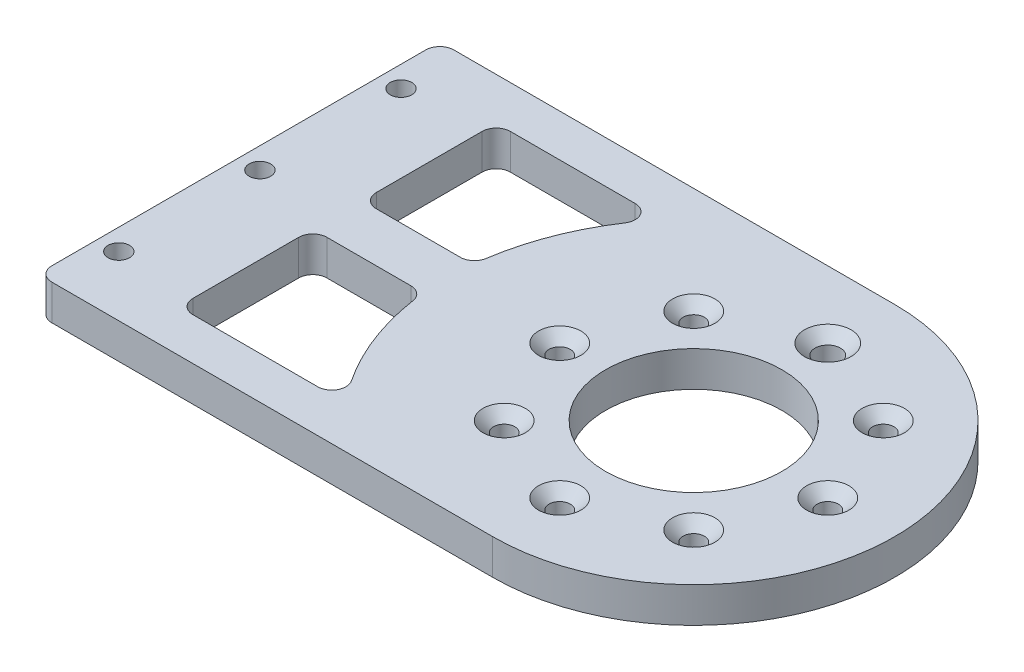
from build123d import *

# Parameters (mm, degrees)
EXTRUDE_1_DEPTH              = 5
SKETCH_2_R                   = 1.275
CUT_EXTRUDE_1_DEPTH          = 6
SKETCH_5_R                   = 10
CUT_EXTRUDE_3_DEPTH          = 6
SKETCH_6_R                   = 1.525
CUT_EXTRUDE_4_DEPTH          = 6
SKETCH_9_R                   = 12.5
CUT_EXTRUDE_7_DEPTH          = 6
HOLE_WIZARD_M3_1_D           = 3.6
HOLE_WIZARD_M3_1_CSINK_D     = 6.6
HOLE_WIZARD_M3_1_CSINK_ANGLE = 90
HOLE_WIZARD_1_D              = 3
HOLE_WIZARD_1_CSINK_D        = 6
HOLE_WIZARD_1_CSINK_ANGLE    = 90
SKETCH_3_R                   = 2.025
CUT_EXTRUDE_8_DEPTH          = 10
SKETCH_14_R                  = 37
EXTRUDE_2_DEPTH              = 5
SKETCH_15_R                  = 42.5
EXTRUDE_3_DEPTH              = 5
SKETCH_16_R                  = 2.025
CUT_EXTRUDE_9_DEPTH          = 5
CUT_EXTRUDE_10_DEPTH         = 5
PATTERN_CIRCULAR_1_COUNT     = 6
SKETCH_19_R                  = 6
CUT_EXTRUDE_11_DEPTH         = 5
FILLET_1_R                   = 2
SKETCH_21_W                  = 189.416251563
SKETCH_21_H                  = 140.293779685
CUT_EXTRUDE_12_DEPTH         = 6
SKETCH_25_R                  = 1.525
CUT_EXTRUDE_13_DEPTH         = 6
FILLET_2_R                   = 2
CUT_EXTRUDE_14_DEPTH         = 6
FILLET_3_R                   = 2


with BuildPart() as part:
    # 草图1 → 凸台-拉伸1 (new body)
    with BuildSketch(Plane(origin=(0, 0, 0), x_dir=(1, 0, 0), z_dir=(0, 1, 0))):
        with BuildLine():
            Line((105, 28.5), (-81.404449572, 28.5))
            ThreePointArc((-81.404449572, 28.5), (-142, 0), (-81.404449572, -28.5))
            Line((-81.404449572, -28.5), (105, -28.5))
            ThreePointArc((105, -28.5), (133.5, 0), (105, 28.5))
        make_face()
    extrude(amount=EXTRUDE_1_DEPTH)

    # 草图2 → 切除-拉伸1 (cut, through all)
    with BuildSketch(Plane.XZ):
        with Locations((118.435028843, 13.435028843)):
            Circle(SKETCH_2_R)
        with Locations((118.435028843, -13.435028843)):
            Circle(SKETCH_2_R)
        with Locations((91.564971157, -13.435028843)):
            Circle(SKETCH_2_R)
        with Locations((91.564971157, 13.435028843)):
            Circle(SKETCH_2_R)
        with Locations((124, 0)):
            Circle(SKETCH_2_R)
        with Locations((105, -19)):
            Circle(SKETCH_2_R)
        with Locations((86, 0)):
            Circle(SKETCH_2_R)
        with Locations((105, 19)):
            Circle(SKETCH_2_R)
    extrude(amount=-CUT_EXTRUDE_1_DEPTH, mode=Mode.SUBTRACT)

    # 草图5 → 切除-拉伸3 (cut, through all)
    with BuildSketch(Plane(origin=(0, 5, 0), x_dir=(1, 0, 0), z_dir=(0, 1, 0))):
        with Locations((-105, 0)):
            Circle(SKETCH_5_R)
    extrude(amount=-CUT_EXTRUDE_3_DEPTH, mode=Mode.SUBTRACT)

    # 草图6 → 切除-拉伸4 (cut, through all)
    with BuildSketch(Plane(origin=(0, 5, 0), x_dir=(1, 0, 0), z_dir=(0, 1, 0))):
        with Locations((-135, 0)):
            Circle(SKETCH_6_R)
        with Locations((-120, 25.980762114)):
            Circle(SKETCH_6_R)
        with Locations((-90, 25.980762114)):
            Circle(SKETCH_6_R)
        with Locations((-75, 0)):
            Circle(SKETCH_6_R)
        with Locations((-90, -25.980762114)):
            Circle(SKETCH_6_R)
        with Locations((-120, -25.980762114)):
            Circle(SKETCH_6_R)
    extrude(amount=-CUT_EXTRUDE_4_DEPTH, mode=Mode.SUBTRACT)

    # 草图9 → 切除-拉伸7 (cut, through all)
    with BuildSketch(Plane.XZ):
        with Locations((105, 0)):
            Circle(SKETCH_9_R)
    extrude(amount=-CUT_EXTRUDE_7_DEPTH, mode=Mode.SUBTRACT)

    # M3 十字槽沉头木螺钉的锥形沉头孔1 (through all)
    with Locations(Plane(origin=(0, 5, 0), x_dir=(1, 0, 0), z_dir=(0, 1, 0))):
        with Locations((105, 19)):
            CounterSinkHole(HOLE_WIZARD_M3_1_D / 2, HOLE_WIZARD_M3_1_CSINK_D / 2, counter_sink_angle=HOLE_WIZARD_M3_1_CSINK_ANGLE)

    # 孔1 (through all)
    with Locations(Plane(origin=(0, 5, 0), x_dir=(1, 0, 0), z_dir=(0, 1, 0))):
        with Locations((91.564971157, 13.435028843), (86, 0), (91.564971157, -13.435028843), (105, -19), (118.435028843, -13.435028843), (124, 0), (118.435028843, 13.435028843)):
            CounterSinkHole(HOLE_WIZARD_1_D / 2, HOLE_WIZARD_1_CSINK_D / 2, counter_sink_angle=HOLE_WIZARD_1_CSINK_ANGLE)

    # 草图3 → 切除-拉伸8 (cut)
    with BuildSketch(Plane(origin=(0, 5, 0), x_dir=(1, 0, 0), z_dir=(0, 1, 0))):
        with Locations((-105, 17.25)):
            Circle(SKETCH_3_R)
        with Locations((-90.061061785, 8.625)):
            Circle(SKETCH_3_R)
        with Locations((-90.061061785, -8.625)):
            Circle(SKETCH_3_R)
        with Locations((-105, -17.25)):
            Circle(SKETCH_3_R)
        with Locations((-119.938938215, -8.625)):
            Circle(SKETCH_3_R)
        with Locations((-119.938938215, 8.625)):
            Circle(SKETCH_3_R)
    extrude(amount=-CUT_EXTRUDE_8_DEPTH, mode=Mode.SUBTRACT)

    # 草图14 → 凸台-拉伸2 (add)
    with BuildSketch(Plane(origin=(0, 5, 0), x_dir=(1, 0, 0), z_dir=(0, 1, 0))):
        with Locations((-105, 0)):
            Circle(SKETCH_14_R)
    extrude(amount=-EXTRUDE_2_DEPTH)

    # 草图15 → 凸台-拉伸3 (add)
    with BuildSketch(Plane(origin=(0, 5, 0), x_dir=(1, 0, 0), z_dir=(0, 1, 0))):
        with Locations((-105, 0)):
            Circle(SKETCH_15_R)
    extrude(amount=-EXTRUDE_3_DEPTH)

    # 草图16 → 切除-拉伸9 (cut)
    with BuildSketch(Plane.XZ):
        with Locations((-105, 26.25)):
            Circle(SKETCH_16_R)
        with Locations((-86.438446994, 18.561553006)):
            Circle(SKETCH_16_R)
        with Locations((-78.75, 0)):
            Circle(SKETCH_16_R)
        with Locations((-86.438446994, -18.561553006)):
            Circle(SKETCH_16_R)
        with Locations((-105, -26.25)):
            Circle(SKETCH_16_R)
        with Locations((-123.561553006, -18.561553006)):
            Circle(SKETCH_16_R)
        with Locations((-131.25, 0)):
            Circle(SKETCH_16_R)
        with Locations((-123.561553006, 18.561553006)):
            Circle(SKETCH_16_R)
    extrude(amount=-CUT_EXTRUDE_9_DEPTH, mode=Mode.SUBTRACT)

    # 草图18 → 切除-拉伸10 (cut)
    with BuildSketch(Plane(origin=(0, 5, 0), x_dir=(1, 0, 0), z_dir=(0, 1, 0))):
        with BuildLine():
            Line((-98.815341562, 17.25), (-101.45814062, 12.173230244))
            ThreePointArc((-101.45814062, 12.173230244), (-105, 13), (-108.54185938, 12.173230244))
            Line((-108.54185938, 12.173230244), (-111.184658438, 17.25))
            ThreePointArc((-111.184658438, 17.25), (-105, 21.75), (-98.815341562, 17.25))
        make_face()
    cut_extrude_10 = extrude(amount=-CUT_EXTRUDE_10_DEPTH, mode=Mode.SUBTRACT)

    # 阵列(圆周)1: 切除-拉伸10 ×6 about axis
    pattern_circular_1_axis = Axis((-105, 0, 0), (0, 1, 0))
    for i in range(1, PATTERN_CIRCULAR_1_COUNT):
        add(cut_extrude_10.rotate(pattern_circular_1_axis, i * 360 / PATTERN_CIRCULAR_1_COUNT), mode=Mode.SUBTRACT)

    # 草图19 → 切除-拉伸11 (cut)
    with BuildSketch(Plane.XZ):
        with Locations((-105, 0)):
            Circle(SKETCH_19_R)
    extrude(amount=-CUT_EXTRUDE_11_DEPTH, mode=Mode.SUBTRACT)

    # 圆角1
    fillet_1_edges = [part.edges().sort_by_distance(p)[0] for p in [
        (-73.472234459, 2.5, 28.5),
        (-73.472234459, 2.5, -28.5),
    ]]
    fillet(fillet_1_edges, radius=FILLET_1_R)

    # 草图21 → 切除-拉伸12 (cut, through all)
    with BuildSketch(Plane.XZ):
        with Locations((-54.208125782, -1.277184269)):
            Rectangle(SKETCH_21_W, SKETCH_21_H)
    extrude(amount=-CUT_EXTRUDE_12_DEPTH, mode=Mode.SUBTRACT)

    # 草图25 → 切除-拉伸13 (cut, through all)
    with BuildSketch(Plane.XZ):
        with Locations((43.5, 0)):
            Circle(SKETCH_25_R)
        with Locations((43.5, 20)):
            Circle(SKETCH_25_R)
        with Locations((43.5, -20)):
            Circle(SKETCH_25_R)
    extrude(amount=-CUT_EXTRUDE_13_DEPTH, mode=Mode.SUBTRACT)

    # 圆角2
    fillet_2_edges = [part.edges().sort_by_distance(p)[0] for p in [
        (40.5, 2.5, -28.5),
        (40.5, 2.5, 28.5),
    ]]
    fillet(fillet_2_edges, radius=FILLET_2_R)

    # 草图28 → 切除-拉伸14 (cut, through all)
    with BuildSketch(Plane.XZ):
        with BuildLine():
            ThreePointArc((70.175439701, 3.5), (72.751903077, 13.603684973), (78.190486763, 22.5))
            Line((78.190486763, 22.5), (54.5, 22.5))
            Line((54.5, 22.5), (54.5, 3.5))
            Line((54.5, 3.5), (70.175439701, 3.5))
        make_face()
        with BuildLine():
            Line((54.5, -3.5), (54.5, -22.5))
            Line((54.5, -22.5), (78.190486763, -22.5))
            ThreePointArc((78.190486763, -22.5), (72.751903077, -13.603684973), (70.175439701, -3.5))
            Line((70.175439701, -3.5), (54.5, -3.5))
        make_face()
    extrude(amount=-CUT_EXTRUDE_14_DEPTH, mode=Mode.SUBTRACT)

    # 圆角3
    fillet_3_edges = [part.edges().sort_by_distance(p)[0] for p in [
        (78.190486763, 2.5, 22.5),
        (70.175439701, 2.5, 3.5),
        (54.5, 2.5, 3.5),
        (54.5, 2.5, 22.5),
        (70.175439701, 2.5, -3.5),
        (78.190486763, 2.5, -22.5),
        (54.5, 2.5, -22.5),
        (54.5, 2.5, -3.5),
    ]]
    fillet(fillet_3_edges, radius=FILLET_3_R)


solid = part.part
